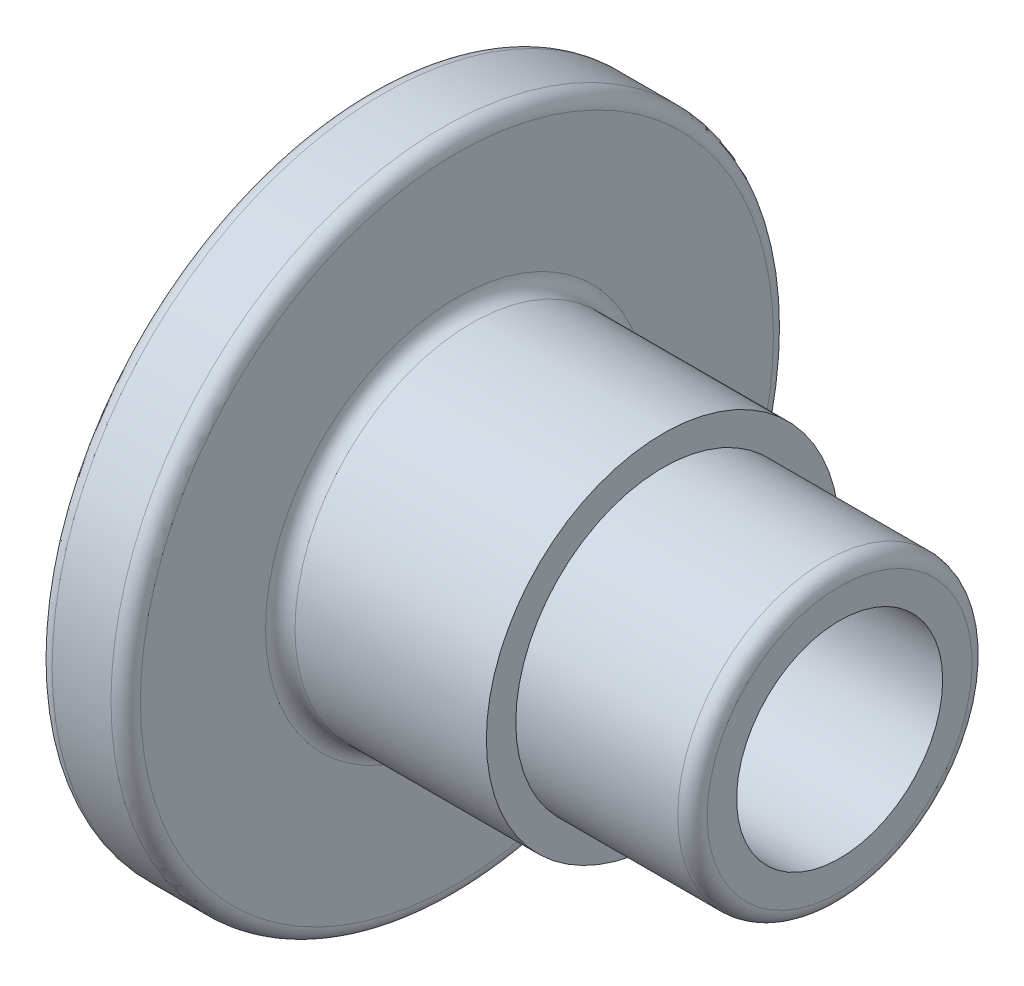
from build123d import *

# Parameters (mm, degrees)
FILLET1_R             = 0.5
M8X1_0_TAPPED_HOLE1_D = 7
SKETCH4_R             = 5
CUT_EXTRUDE1_DEPTH    = 5


with BuildPart() as part:
    # Sketch1 → Revolve1 (revolve)
    with BuildSketch(Plane.XY):
        Polygon((0, 0), (0, 11.25), (3, 11.25), (3, 6), (10, 6), (10, 5), (16, 5), (16, 0), align=None)
    revolve(axis=Axis((0, 0, 0), (1, 0, 0)))

    # Fillet1
    fillet1_edges = [part.edges().sort_by_distance(p)[0] for p in [
        (16, -5, 0),
        (3, -6, 0),
        (3, -11.25, 0),
        (0, -11.25, 0),
    ]]
    fillet(fillet1_edges, radius=FILLET1_R)

    # M8x1.0 Tapped Hole1 (through all)
    with Locations(Plane(origin=(16, 0, 0), x_dir=(0, 0, -1), z_dir=(1, 0, 0))):
        with Locations((0, 0)):
            Hole(M8X1_0_TAPPED_HOLE1_D / 2)

    # Sketch4 → Cut-Extrude1 (cut)
    with BuildSketch(Plane.ZY):
        Circle(SKETCH4_R)
    extrude(amount=-CUT_EXTRUDE1_DEPTH, mode=Mode.SUBTRACT)


solid = part.part
